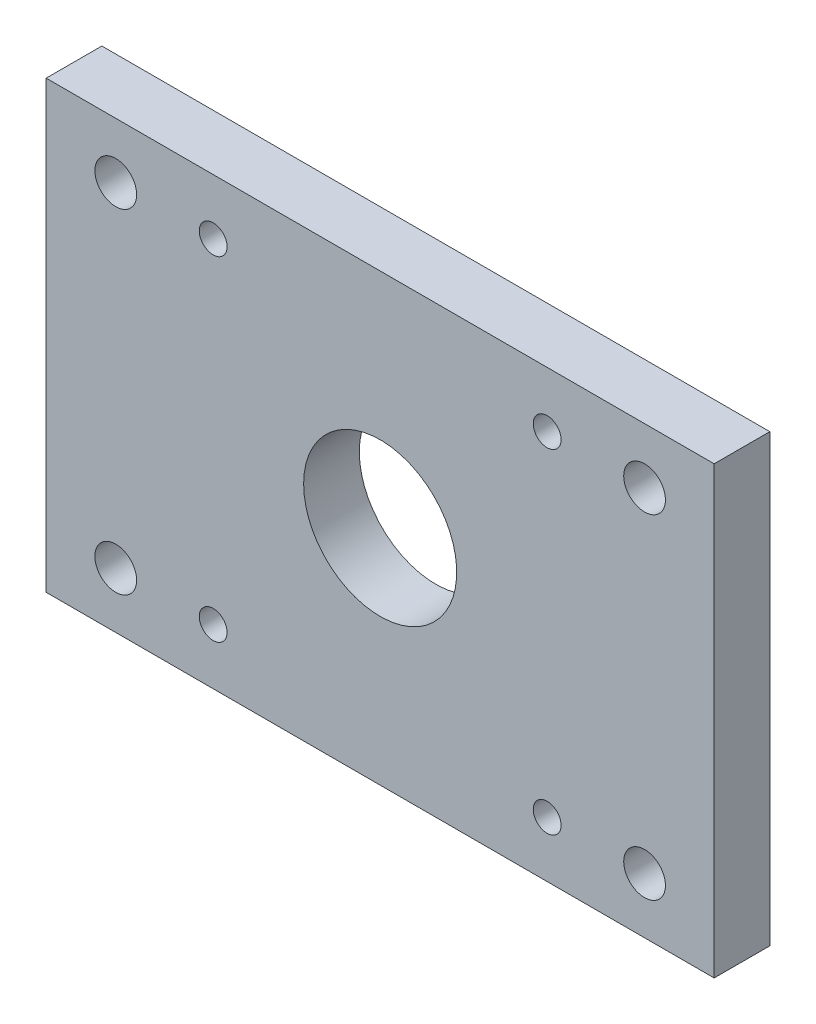
from build123d import *

# Parameters (mm, degrees)
SKETCH1_W               = 76.2
SKETCH1_H               = 50.8
BOSS_EXTRUDE1_DEPTH     = 6.35
SKETCH3_R               = 2.38125
CUT_EXTRUDE6_DEPTH      = 7.35
MIRROR2_COPY_1_SKETCH_R = 2.38125
MIRROR2_COPY_1_DEPTH    = 7.35
SKETCH2_R               = 8.73125
CUT_EXTRUDE7_DEPTH      = 7.35
SKETCH5_R               = 1.5875
CUT_EXTRUDE8_DEPTH      = 7.35


with BuildPart() as part:
    # Sketch1 → Boss-Extrude1 (new body)
    with BuildSketch(Plane.XY):
        with Locations((38.1, 25.4)):
            Rectangle(SKETCH1_W, SKETCH1_H)
    extrude(amount=BOSS_EXTRUDE1_DEPTH)

    # Sketch3 → Cut-Extrude6 (cut, through all)
    with BuildSketch(Plane(origin=(0, 0, 0), x_dir=(-1, 0, 0), z_dir=(0, 0, -1))):
        with Locations((-68.2625, 44.45)):
            Circle(SKETCH3_R)
    cut_extrude6 = extrude(amount=-CUT_EXTRUDE6_DEPTH, mode=Mode.SUBTRACT)

    # Mirror1: Cut-Extrude6 across plane
    add(cut_extrude6.mirror(Plane(origin=(38.1, 0, 0), x_dir=(0, 0, 1), z_dir=(1, 0, 0))), mode=Mode.SUBTRACT)

    # Mirror2: Cut-Extrude6 across plane
    add(cut_extrude6.mirror(Plane(origin=(0, 25.4, 0), x_dir=(0, 0, 1), z_dir=(0, -1, 0))), mode=Mode.SUBTRACT)

    # Mirror2 copy 1 sketch → Mirror2 copy 1 (cut, through all)
    with BuildSketch(Plane(origin=(76.2, 50.8, 0), x_dir=(1, 0, 0), z_dir=(0, 0, -1))):
        with Locations((-68.2625, 44.45)):
            Circle(MIRROR2_COPY_1_SKETCH_R)
    extrude(amount=-MIRROR2_COPY_1_DEPTH, mode=Mode.SUBTRACT)

    # Sketch2 → Cut-Extrude7 (cut, through all)
    with BuildSketch(Plane(origin=(0, 0, 0), x_dir=(-1, 0, 0), z_dir=(0, 0, -1))):
        with Locations((-38.1, 25.4)):
            Circle(SKETCH2_R)
    extrude(amount=-CUT_EXTRUDE7_DEPTH, mode=Mode.SUBTRACT)

    # Sketch5 → Cut-Extrude8 (cut, through all)
    with BuildSketch(Plane(origin=(0, 0, 0), x_dir=(-1, 0, 0), z_dir=(0, 0, -1))):
        with Locations((-19.05, 44.45)):
            Circle(SKETCH5_R)
        with Locations((-19.05, 6.35)):
            Circle(SKETCH5_R)
        with Locations((-57.15, 44.45)):
            Circle(SKETCH5_R)
        with Locations((-57.15, 6.35)):
            Circle(SKETCH5_R)
    extrude(amount=-CUT_EXTRUDE8_DEPTH, mode=Mode.SUBTRACT)


solid = part.part
